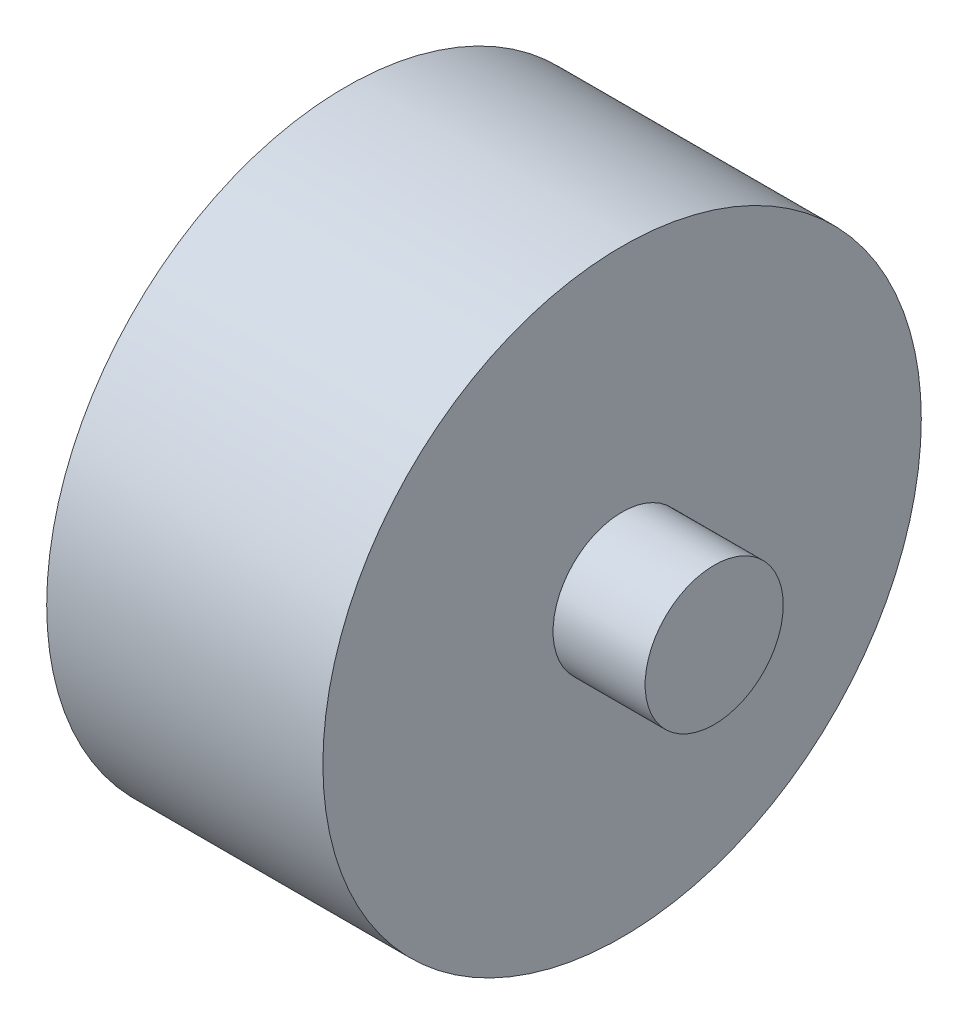
from build123d import *

# Parameters (mm, degrees)
SKETCH1_R           = 65
BOSS_EXTRUDE1_DEPTH = 60
SKETCH2_R           = 15
BOSS_EXTRUDE2_DEPTH = 20


with BuildPart() as part:
    # Sketch1 → Boss-Extrude1 (new body)
    with BuildSketch(Plane(origin=(0, 0, 0), x_dir=(0, 0, -1), z_dir=(1, 0, 0))):
        Circle(SKETCH1_R)
    extrude(amount=BOSS_EXTRUDE1_DEPTH)

    # Sketch2 → Boss-Extrude2 (add)
    with BuildSketch(Plane(origin=(60, 0, 0), x_dir=(0, 0, -1), z_dir=(1, 0, 0))):
        Circle(SKETCH2_R)
    extrude(amount=BOSS_EXTRUDE2_DEPTH)


solid = part.part
